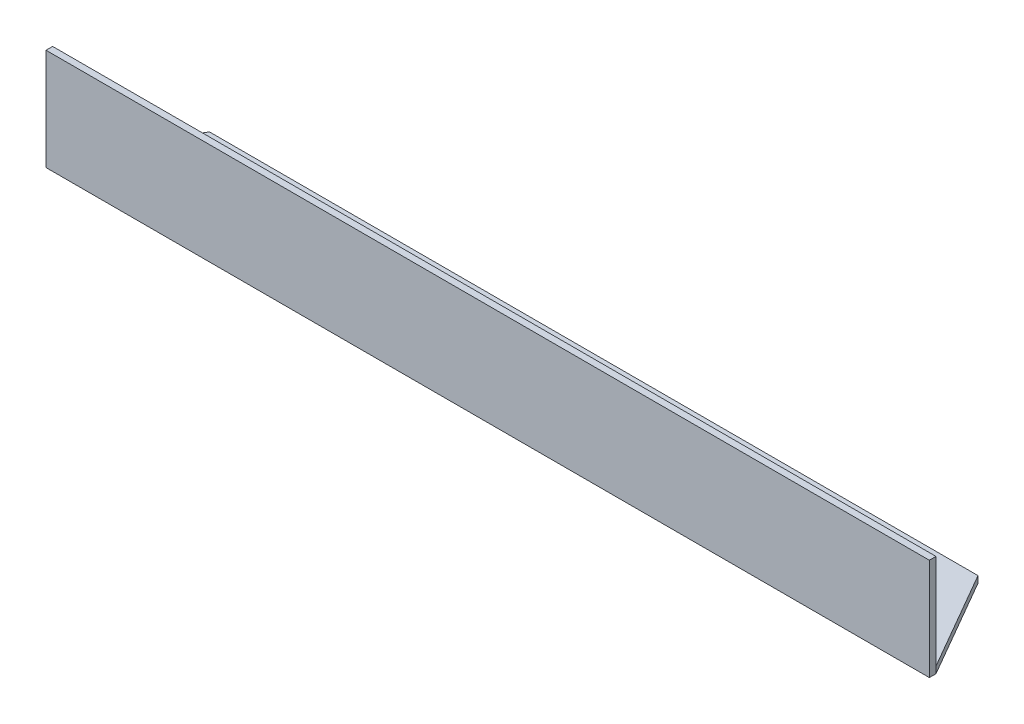
from build123d import *

# Parameters (mm, degrees)
SKETCH18_W          = 200
SKETCH18_H          = 23.014216905
BOSS_EXTRUDE4_DEPTH = 1.5
BOSS_EXTRUDE5_DEPTH = 1.5


with BuildPart() as part:
    # Sketch18 → Boss-Extrude4 (new body)
    with BuildSketch(Plane.XY):
        with Locations((39.219715871, 11.507108453)):
            Rectangle(SKETCH18_W, SKETCH18_H)
    extrude(amount=BOSS_EXTRUDE4_DEPTH)

    # Sketch16 → Boss-Extrude5 (add)
    with BuildSketch(Plane(origin=(0, 0, 0), x_dir=(1, 0, 0), z_dir=(0, 1, 0))):
        Polygon((-47.784100803, 22.510049826), (126.22317902, 22.510049826), (139.219715871, 0), (-60.780284129, 0), align=None)
    extrude(amount=BOSS_EXTRUDE5_DEPTH)


solid = part.part
